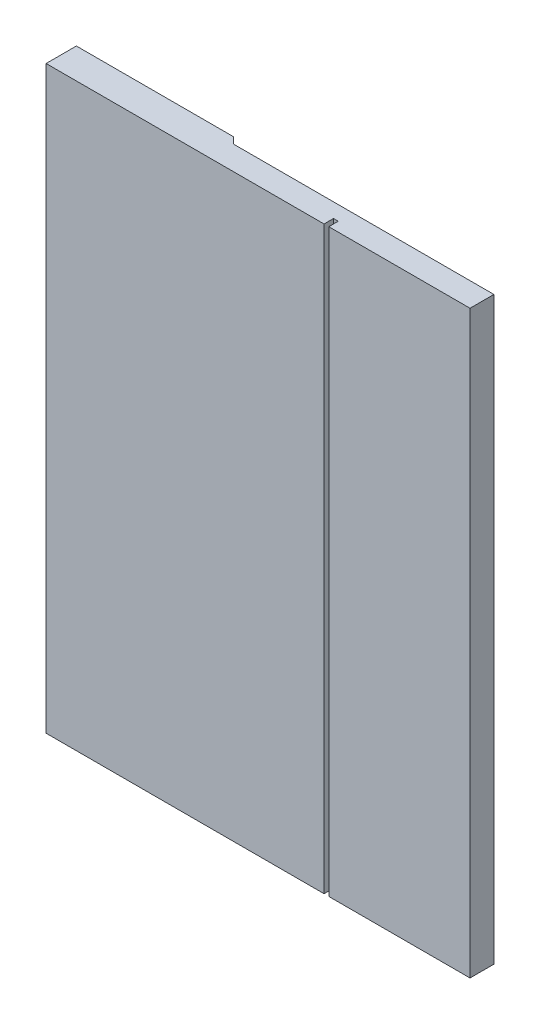
from build123d import *

# Parameters (mm, degrees)
BOSS_EXTRUDE1_DEPTH     = 122.6
SKETCH2_W               = 52.856609426
SKETCH2_H               = 136.885065439
CUT_EXTRUDE1_DEPTH      = 1.4
CUT_EXTRUDE2_DEPTH      = 1
CUT_EXTRUDE2_DEPTH_BACK = 123.6


with BuildPart() as part:
    # Sketch1 → Boss-Extrude1 (new body)
    with BuildSketch(Plane(origin=(0, 0, 0), x_dir=(1, 0, 0), z_dir=(0, 1, 0))):
        Polygon((-4.75, 15), (-4.75, 5.05), (-14.75, 5.05), (-14.75, 6.4), (-91, 6.4), (-91, 0), (-32.25, 0), (-32.25, 2), (-31.25, 2), (-31.25, 0), (0, 0), (0, 15), align=None)
    extrude(amount=BOSS_EXTRUDE1_DEPTH)

    # Sketch2 → Cut-Extrude1 (cut)
    with BuildSketch(Plane(origin=(0, 0, 0), x_dir=(0, 0, -1), z_dir=(1, 0, 0))):
        with Locations((4.111755806, 55.794103185)):
            Rectangle(SKETCH2_W, SKETCH2_H)
    extrude(amount=-CUT_EXTRUDE1_DEPTH, mode=Mode.SUBTRACT)

    # Sketch3 → Cut-Extrude2 (cut, two sides)
    with BuildSketch(Plane(origin=(0, 122.6, 0), x_dir=(1, 0, 0), z_dir=(0, 1, 0))) as cut_extrude2_sk:
        Polygon((-1.4, 5.05), (-56.4, 5.05), (-60.82107113, 9.47107113), (-60.82107113, 21.013712959), (-1.4, 21.013712959), align=None)
    extrude(amount=CUT_EXTRUDE2_DEPTH, mode=Mode.SUBTRACT)
    extrude(cut_extrude2_sk.sketch, amount=-CUT_EXTRUDE2_DEPTH_BACK, mode=Mode.SUBTRACT)


solid = part.part
